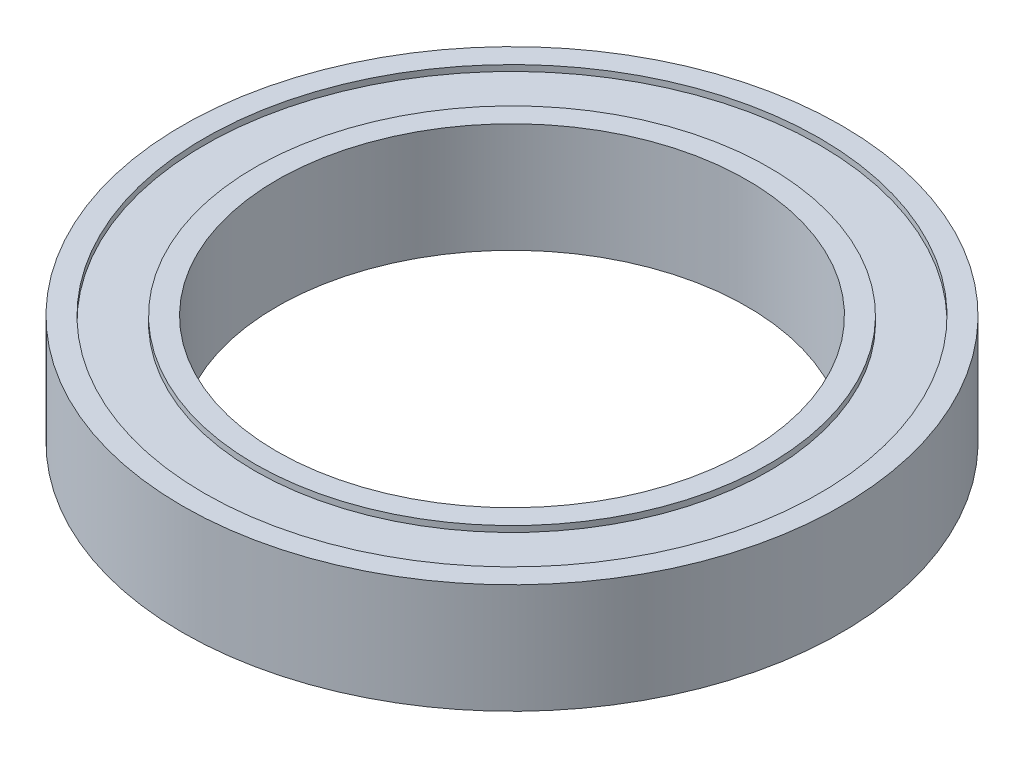
from build123d import *

# Parameters (mm, degrees)
BOSS_EXTRUDE1_DEPTH        = 3.4925
BOSS_EXTRUDE1_DEPTH_BACK   = 3.4925
SKETCH1_R                  = 21.0058
SKETCH1_R_2                = 19.6088
BOSS_EXTRUDE1_2_DEPTH      = 3.4925
BOSS_EXTRUDE1_2_DEPTH_BACK = 3.4925
SKETCH1_R_3                = 16.383
SKETCH1_R_4                = 14.986
BOSS_EXTRUDE2_DEPTH        = 3.1115
BOSS_EXTRUDE2_DEPTH_BACK   = 3.1115
SKETCH1_3_R                = 19.6088
SKETCH1_3_R_2              = 16.383


with BuildPart() as part:
    # Sketch1 → Boss-Extrude1 (new, two sides: drawn at the far end of the back side and taken through both)
    with BuildSketch(Plane(origin=(0, 0, 0), x_dir=(1, 0, 0), z_dir=(0, 1, 0)).offset(-BOSS_EXTRUDE1_DEPTH_BACK)):
        Circle(SKETCH1_R)
        Circle(SKETCH1_R_2, mode=Mode.SUBTRACT)
    extrude(amount=BOSS_EXTRUDE1_DEPTH + BOSS_EXTRUDE1_DEPTH_BACK)



with BuildPart() as body_2:
    # Sketch1 → Boss-Extrude1 2 (new, two sides: drawn at the far end of the back side and taken through both)
    with BuildSketch(Plane(origin=(0, 0, 0), x_dir=(1, 0, 0), z_dir=(0, 1, 0)).offset(-BOSS_EXTRUDE1_2_DEPTH_BACK)):
        Circle(SKETCH1_R_3)
        Circle(SKETCH1_R_4, mode=Mode.SUBTRACT)
    extrude(amount=BOSS_EXTRUDE1_2_DEPTH + BOSS_EXTRUDE1_2_DEPTH_BACK)


with BuildPart() as part_1:
    add(part.part)

    add(body_2.part)  # Boss-Extrude2 merges body 2
    # Sketch1_3 → Boss-Extrude2 (add, two sides: drawn at the far end of the back side and taken through both)
    with BuildSketch(Plane(origin=(0, 0, 0), x_dir=(1, 0, 0), z_dir=(0, 1, 0)).offset(-BOSS_EXTRUDE2_DEPTH_BACK)):
        Circle(SKETCH1_3_R)
        Circle(SKETCH1_3_R_2, mode=Mode.SUBTRACT)
    extrude(amount=BOSS_EXTRUDE2_DEPTH + BOSS_EXTRUDE2_DEPTH_BACK)


solid = part_1.part
